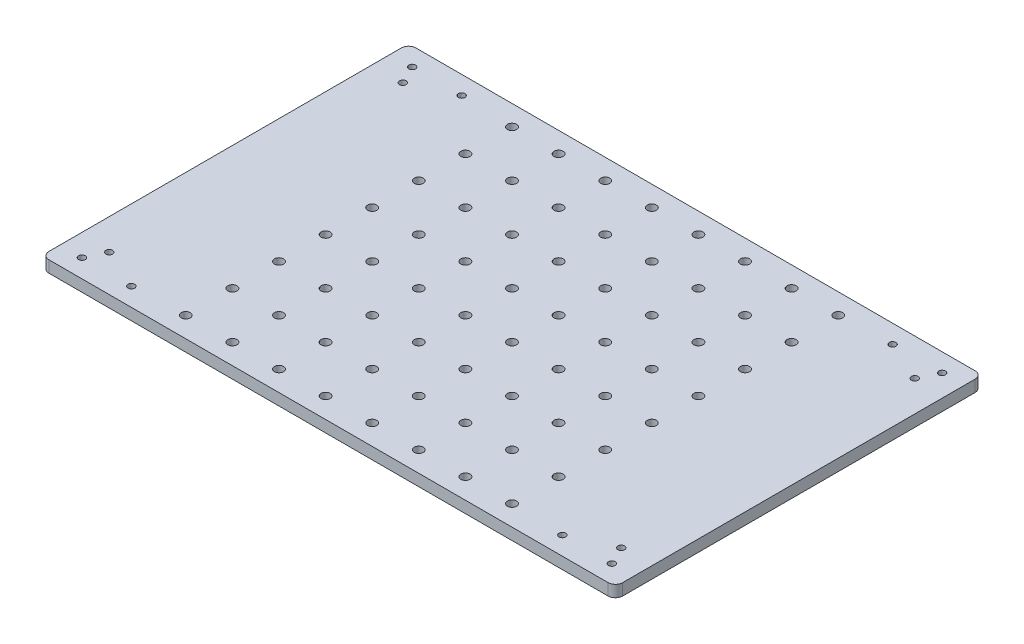
from build123d import *

# Parameters (mm, degrees)
SKETCH1_W                      = 312.7
SKETCH1_H                      = 200
BOSS_EXTRUDE1_DEPTH            = 6.35
FILLET1_R                      = 4
F_6_CLEARANCE_HOLE1_AT_2_COUNT = 2
F_6_CLEARANCE_HOLE1_AT_2_PITCH = 26.9494
F_6_CLEARANCE_HOLE1_AT_3_COUNT = 2
F_6_CLEARANCE_HOLE1_AT_3_PITCH = 11.125788882
LPATTERN2_COUNT                = 8
LPATTERN2_PITCH                = 25.4
LPATTERN3_COUNT                = 8
LPATTERN3_PITCH                = 25.4


with BuildPart() as part:
    # Sketch1 → Boss-Extrude1 (new body)
    with BuildSketch(Plane(origin=(0, 0, 0), x_dir=(1, 0, 0), z_dir=(0, 1, 0))):
        Rectangle(SKETCH1_W, SKETCH1_H)
    extrude(amount=BOSS_EXTRUDE1_DEPTH)

    # Fillet1
    fillet1_edges = [part.edges().sort_by_distance(p)[0] for p in [
        (156.35, 3.175, 100),
        (-156.35, 3.175, 100),
        (-156.35, 3.175, -100),
        (156.35, 3.175, -100),
    ]]
    fillet(fillet1_edges, radius=FILLET1_R)

    # Sketch4 → #6 Clearance Hole1 (revolve, cut)
    with BuildSketch(Plane(origin=(-144.412, 6.35, -90), x_dir=(0, 0, 1), z_dir=(1, 0, 0))):
        Polygon((0, 0), (0, 7.4488539), (1.8288, 6.35), (1.8288, 0), align=None)
    f_6_clearance_hole1 = revolve(axis=Axis((-144.412, 12.7, -90), (0, -1, 0)), mode=Mode.SUBTRACT)

    # #6 Clearance Hole1 at 2: #6 Clearance Hole1 ×2
    with Locations(*[(i * F_6_CLEARANCE_HOLE1_AT_2_PITCH, 0, 0) for i in range(1, F_6_CLEARANCE_HOLE1_AT_2_COUNT)]):
        add(f_6_clearance_hole1, mode=Mode.SUBTRACT)

    # #6 Clearance Hole1 at 3: #6 Clearance Hole1 ×2
    with Locations(*[Vector(0.438332962, 0, 0.898812669) * (i * F_6_CLEARANCE_HOLE1_AT_3_PITCH) for i in range(1, F_6_CLEARANCE_HOLE1_AT_3_COUNT)]):
        add(f_6_clearance_hole1, mode=Mode.SUBTRACT)

    # Mirror1: #6 Clearance Hole1 across plane
    add(f_6_clearance_hole1.mirror(Plane.XY), mode=Mode.SUBTRACT)

    # Mirror1 copy 1 sketch → Mirror1 copy 1 (revolve, cut)
    with BuildSketch(Plane(origin=(-117.4626, 6.35, 90), x_dir=(0, 0, -1), z_dir=(1, 0, 0))):
        Polygon((0, 0), (0, -7.4488539), (1.8288, -6.35), (1.8288, 0), align=None)
    revolve(axis=Axis((-117.4626, 12.7, 90), (0, 1, 0)), mode=Mode.SUBTRACT)

    # Mirror1 copy 2 sketch → Mirror1 copy 2 (revolve, cut)
    with BuildSketch(Plane(origin=(-139.5352, 6.35, 80), x_dir=(0, 0, -1), z_dir=(1, 0, 0))):
        Polygon((0, 0), (0, -7.4488539), (1.8288, -6.35), (1.8288, 0), align=None)
    revolve(axis=Axis((-139.5352, 12.7, 80), (0, 1, 0)), mode=Mode.SUBTRACT)

    # Mirror2: #6 Clearance Hole1 across plane
    add(f_6_clearance_hole1.mirror(Plane(origin=(0, 0, 0), x_dir=(0, 0, 1), z_dir=(1, 0, 0))), mode=Mode.SUBTRACT)

    # Mirror2 copy 1 sketch → Mirror2 copy 1 (revolve, cut)
    with BuildSketch(Plane(origin=(144.412, 6.35, 90), x_dir=(0, 0, -1), z_dir=(-1, 0, 0))):
        Polygon((0, 0), (0, 7.4488539), (1.8288, 6.35), (1.8288, 0), align=None)
    revolve(axis=Axis((144.412, 12.7, 90), (0, -1, 0)), mode=Mode.SUBTRACT)

    # Mirror2 copy 2 sketch → Mirror2 copy 2 (revolve, cut)
    with BuildSketch(Plane(origin=(117.4626, 6.35, 90), x_dir=(0, 0, -1), z_dir=(-1, 0, 0))):
        Polygon((0, 0), (0, 7.4488539), (1.8288, 6.35), (1.8288, 0), align=None)
    revolve(axis=Axis((117.4626, 12.7, 90), (0, -1, 0)), mode=Mode.SUBTRACT)

    # Mirror2 copy 3 sketch → Mirror2 copy 3 (revolve, cut)
    with BuildSketch(Plane(origin=(139.5352, 6.35, 80), x_dir=(0, 0, -1), z_dir=(-1, 0, 0))):
        Polygon((0, 0), (0, 7.4488539), (1.8288, 6.35), (1.8288, 0), align=None)
    revolve(axis=Axis((139.5352, 12.7, 80), (0, -1, 0)), mode=Mode.SUBTRACT)

    # Mirror2 copy 4 sketch → Mirror2 copy 4 (revolve, cut)
    with BuildSketch(Plane(origin=(117.4626, 6.35, -90), x_dir=(0, 0, 1), z_dir=(-1, 0, 0))):
        Polygon((0, 0), (0, -7.4488539), (1.8288, -6.35), (1.8288, 0), align=None)
    revolve(axis=Axis((117.4626, 12.7, -90), (0, 1, 0)), mode=Mode.SUBTRACT)

    # Mirror2 copy 5 sketch → Mirror2 copy 5 (revolve, cut)
    with BuildSketch(Plane(origin=(139.5352, 6.35, -80), x_dir=(0, 0, 1), z_dir=(-1, 0, 0))):
        Polygon((0, 0), (0, -7.4488539), (1.8288, -6.35), (1.8288, 0), align=None)
    revolve(axis=Axis((139.5352, 12.7, -80), (0, 1, 0)), mode=Mode.SUBTRACT)

    # Sketch9 → #10 Clearance Hole3 (revolve, cut)
    with BuildSketch(Plane(origin=(-88.9, 6.35, 88.9), x_dir=(0, 0, 1), z_dir=(1, 0, 0))):
        Polygon((0, 0), (0, 7.845662253), (2.4892, 6.35), (2.4892, 0), align=None)
    f_10_clearance_hole3 = revolve(axis=Axis((-88.9, 12.7, 88.9), (0, -1, 0)), mode=Mode.SUBTRACT)

    # LPattern2: #10 Clearance Hole3 ×8
    with Locations(*[(0, 0, -i * LPATTERN2_PITCH) for i in range(1, LPATTERN2_COUNT)]):
        add(f_10_clearance_hole3, mode=Mode.SUBTRACT)

    # LPattern3: #10 Clearance Hole3 ×8
    with Locations(*[(i * LPATTERN3_PITCH, 0, 0) for i in range(1, LPATTERN3_COUNT)]):
        add(f_10_clearance_hole3, mode=Mode.SUBTRACT)

    # LPattern3 copy 1 sketch → LPattern3 copy 1 (revolve, cut)
    with BuildSketch(Plane(origin=(-63.5, 6.35, 63.5), x_dir=(0, 0, 1), z_dir=(1, 0, 0))):
        Polygon((0, 0), (0, 7.845662253), (2.4892, 6.35), (2.4892, 0), align=None)
    revolve(axis=Axis((-63.5, 12.7, 63.5), (0, -1, 0)), mode=Mode.SUBTRACT)

    # LPattern3 copy 2 sketch → LPattern3 copy 2 (revolve, cut)
    with BuildSketch(Plane(origin=(-38.1, 6.35, 63.5), x_dir=(0, 0, 1), z_dir=(1, 0, 0))):
        Polygon((0, 0), (0, 7.845662253), (2.4892, 6.35), (2.4892, 0), align=None)
    revolve(axis=Axis((-38.1, 12.7, 63.5), (0, -1, 0)), mode=Mode.SUBTRACT)

    # LPattern3 copy 3 sketch → LPattern3 copy 3 (revolve, cut)
    with BuildSketch(Plane(origin=(-12.7, 6.35, 63.5), x_dir=(0, 0, 1), z_dir=(1, 0, 0))):
        Polygon((0, 0), (0, 7.845662253), (2.4892, 6.35), (2.4892, 0), align=None)
    revolve(axis=Axis((-12.7, 12.7, 63.5), (0, -1, 0)), mode=Mode.SUBTRACT)

    # LPattern3 copy 4 sketch → LPattern3 copy 4 (revolve, cut)
    with BuildSketch(Plane(origin=(12.7, 6.35, 63.5), x_dir=(0, 0, 1), z_dir=(1, 0, 0))):
        Polygon((0, 0), (0, 7.845662253), (2.4892, 6.35), (2.4892, 0), align=None)
    revolve(axis=Axis((12.7, 12.7, 63.5), (0, -1, 0)), mode=Mode.SUBTRACT)

    # LPattern3 copy 5 sketch → LPattern3 copy 5 (revolve, cut)
    with BuildSketch(Plane(origin=(38.1, 6.35, 63.5), x_dir=(0, 0, 1), z_dir=(1, 0, 0))):
        Polygon((0, 0), (0, 7.845662253), (2.4892, 6.35), (2.4892, 0), align=None)
    revolve(axis=Axis((38.1, 12.7, 63.5), (0, -1, 0)), mode=Mode.SUBTRACT)

    # LPattern3 copy 6 sketch → LPattern3 copy 6 (revolve, cut)
    with BuildSketch(Plane(origin=(63.5, 6.35, 63.5), x_dir=(0, 0, 1), z_dir=(1, 0, 0))):
        Polygon((0, 0), (0, 7.845662253), (2.4892, 6.35), (2.4892, 0), align=None)
    revolve(axis=Axis((63.5, 12.7, 63.5), (0, -1, 0)), mode=Mode.SUBTRACT)

    # LPattern3 copy 7 sketch → LPattern3 copy 7 (revolve, cut)
    with BuildSketch(Plane(origin=(88.9, 6.35, 63.5), x_dir=(0, 0, 1), z_dir=(1, 0, 0))):
        Polygon((0, 0), (0, 7.845662253), (2.4892, 6.35), (2.4892, 0), align=None)
    revolve(axis=Axis((88.9, 12.7, 63.5), (0, -1, 0)), mode=Mode.SUBTRACT)

    # LPattern3 copy 8 sketch → LPattern3 copy 8 (revolve, cut)
    with BuildSketch(Plane(origin=(-63.5, 6.35, 38.1), x_dir=(0, 0, 1), z_dir=(1, 0, 0))):
        Polygon((0, 0), (0, 7.845662253), (2.4892, 6.35), (2.4892, 0), align=None)
    revolve(axis=Axis((-63.5, 12.7, 38.1), (0, -1, 0)), mode=Mode.SUBTRACT)

    # LPattern3 copy 9 sketch → LPattern3 copy 9 (revolve, cut)
    with BuildSketch(Plane(origin=(-38.1, 6.35, 38.1), x_dir=(0, 0, 1), z_dir=(1, 0, 0))):
        Polygon((0, 0), (0, 7.845662253), (2.4892, 6.35), (2.4892, 0), align=None)
    revolve(axis=Axis((-38.1, 12.7, 38.1), (0, -1, 0)), mode=Mode.SUBTRACT)

    # LPattern3 copy 10 sketch → LPattern3 copy 10 (revolve, cut)
    with BuildSketch(Plane(origin=(-12.7, 6.35, 38.1), x_dir=(0, 0, 1), z_dir=(1, 0, 0))):
        Polygon((0, 0), (0, 7.845662253), (2.4892, 6.35), (2.4892, 0), align=None)
    revolve(axis=Axis((-12.7, 12.7, 38.1), (0, -1, 0)), mode=Mode.SUBTRACT)

    # LPattern3 copy 11 sketch → LPattern3 copy 11 (revolve, cut)
    with BuildSketch(Plane(origin=(12.7, 6.35, 38.1), x_dir=(0, 0, 1), z_dir=(1, 0, 0))):
        Polygon((0, 0), (0, 7.845662253), (2.4892, 6.35), (2.4892, 0), align=None)
    revolve(axis=Axis((12.7, 12.7, 38.1), (0, -1, 0)), mode=Mode.SUBTRACT)

    # LPattern3 copy 12 sketch → LPattern3 copy 12 (revolve, cut)
    with BuildSketch(Plane(origin=(38.1, 6.35, 38.1), x_dir=(0, 0, 1), z_dir=(1, 0, 0))):
        Polygon((0, 0), (0, 7.845662253), (2.4892, 6.35), (2.4892, 0), align=None)
    revolve(axis=Axis((38.1, 12.7, 38.1), (0, -1, 0)), mode=Mode.SUBTRACT)

    # LPattern3 copy 13 sketch → LPattern3 copy 13 (revolve, cut)
    with BuildSketch(Plane(origin=(63.5, 6.35, 38.1), x_dir=(0, 0, 1), z_dir=(1, 0, 0))):
        Polygon((0, 0), (0, 7.845662253), (2.4892, 6.35), (2.4892, 0), align=None)
    revolve(axis=Axis((63.5, 12.7, 38.1), (0, -1, 0)), mode=Mode.SUBTRACT)

    # LPattern3 copy 14 sketch → LPattern3 copy 14 (revolve, cut)
    with BuildSketch(Plane(origin=(88.9, 6.35, 38.1), x_dir=(0, 0, 1), z_dir=(1, 0, 0))):
        Polygon((0, 0), (0, 7.845662253), (2.4892, 6.35), (2.4892, 0), align=None)
    revolve(axis=Axis((88.9, 12.7, 38.1), (0, -1, 0)), mode=Mode.SUBTRACT)

    # LPattern3 copy 15 sketch → LPattern3 copy 15 (revolve, cut)
    with BuildSketch(Plane(origin=(-63.5, 6.35, 12.7), x_dir=(0, 0, 1), z_dir=(1, 0, 0))):
        Polygon((0, 0), (0, 7.845662253), (2.4892, 6.35), (2.4892, 0), align=None)
    revolve(axis=Axis((-63.5, 12.7, 12.7), (0, -1, 0)), mode=Mode.SUBTRACT)

    # LPattern3 copy 16 sketch → LPattern3 copy 16 (revolve, cut)
    with BuildSketch(Plane(origin=(-38.1, 6.35, 12.7), x_dir=(0, 0, 1), z_dir=(1, 0, 0))):
        Polygon((0, 0), (0, 7.845662253), (2.4892, 6.35), (2.4892, 0), align=None)
    revolve(axis=Axis((-38.1, 12.7, 12.7), (0, -1, 0)), mode=Mode.SUBTRACT)

    # LPattern3 copy 17 sketch → LPattern3 copy 17 (revolve, cut)
    with BuildSketch(Plane(origin=(-12.7, 6.35, 12.7), x_dir=(0, 0, 1), z_dir=(1, 0, 0))):
        Polygon((0, 0), (0, 7.845662253), (2.4892, 6.35), (2.4892, 0), align=None)
    revolve(axis=Axis((-12.7, 12.7, 12.7), (0, -1, 0)), mode=Mode.SUBTRACT)

    # LPattern3 copy 18 sketch → LPattern3 copy 18 (revolve, cut)
    with BuildSketch(Plane(origin=(12.7, 6.35, 12.7), x_dir=(0, 0, 1), z_dir=(1, 0, 0))):
        Polygon((0, 0), (0, 7.845662253), (2.4892, 6.35), (2.4892, 0), align=None)
    revolve(axis=Axis((12.7, 12.7, 12.7), (0, -1, 0)), mode=Mode.SUBTRACT)

    # LPattern3 copy 19 sketch → LPattern3 copy 19 (revolve, cut)
    with BuildSketch(Plane(origin=(38.1, 6.35, 12.7), x_dir=(0, 0, 1), z_dir=(1, 0, 0))):
        Polygon((0, 0), (0, 7.845662253), (2.4892, 6.35), (2.4892, 0), align=None)
    revolve(axis=Axis((38.1, 12.7, 12.7), (0, -1, 0)), mode=Mode.SUBTRACT)

    # LPattern3 copy 20 sketch → LPattern3 copy 20 (revolve, cut)
    with BuildSketch(Plane(origin=(63.5, 6.35, 12.7), x_dir=(0, 0, 1), z_dir=(1, 0, 0))):
        Polygon((0, 0), (0, 7.845662253), (2.4892, 6.35), (2.4892, 0), align=None)
    revolve(axis=Axis((63.5, 12.7, 12.7), (0, -1, 0)), mode=Mode.SUBTRACT)

    # LPattern3 copy 21 sketch → LPattern3 copy 21 (revolve, cut)
    with BuildSketch(Plane(origin=(88.9, 6.35, 12.7), x_dir=(0, 0, 1), z_dir=(1, 0, 0))):
        Polygon((0, 0), (0, 7.845662253), (2.4892, 6.35), (2.4892, 0), align=None)
    revolve(axis=Axis((88.9, 12.7, 12.7), (0, -1, 0)), mode=Mode.SUBTRACT)

    # LPattern3 copy 22 sketch → LPattern3 copy 22 (revolve, cut)
    with BuildSketch(Plane(origin=(-63.5, 6.35, -12.7), x_dir=(0, 0, 1), z_dir=(1, 0, 0))):
        Polygon((0, 0), (0, 7.845662253), (2.4892, 6.35), (2.4892, 0), align=None)
    revolve(axis=Axis((-63.5, 12.7, -12.7), (0, -1, 0)), mode=Mode.SUBTRACT)

    # LPattern3 copy 23 sketch → LPattern3 copy 23 (revolve, cut)
    with BuildSketch(Plane(origin=(-38.1, 6.35, -12.7), x_dir=(0, 0, 1), z_dir=(1, 0, 0))):
        Polygon((0, 0), (0, 7.845662253), (2.4892, 6.35), (2.4892, 0), align=None)
    revolve(axis=Axis((-38.1, 12.7, -12.7), (0, -1, 0)), mode=Mode.SUBTRACT)

    # LPattern3 copy 24 sketch → LPattern3 copy 24 (revolve, cut)
    with BuildSketch(Plane(origin=(-12.7, 6.35, -12.7), x_dir=(0, 0, 1), z_dir=(1, 0, 0))):
        Polygon((0, 0), (0, 7.845662253), (2.4892, 6.35), (2.4892, 0), align=None)
    revolve(axis=Axis((-12.7, 12.7, -12.7), (0, -1, 0)), mode=Mode.SUBTRACT)

    # LPattern3 copy 25 sketch → LPattern3 copy 25 (revolve, cut)
    with BuildSketch(Plane(origin=(12.7, 6.35, -12.7), x_dir=(0, 0, 1), z_dir=(1, 0, 0))):
        Polygon((0, 0), (0, 7.845662253), (2.4892, 6.35), (2.4892, 0), align=None)
    revolve(axis=Axis((12.7, 12.7, -12.7), (0, -1, 0)), mode=Mode.SUBTRACT)

    # LPattern3 copy 26 sketch → LPattern3 copy 26 (revolve, cut)
    with BuildSketch(Plane(origin=(38.1, 6.35, -12.7), x_dir=(0, 0, 1), z_dir=(1, 0, 0))):
        Polygon((0, 0), (0, 7.845662253), (2.4892, 6.35), (2.4892, 0), align=None)
    revolve(axis=Axis((38.1, 12.7, -12.7), (0, -1, 0)), mode=Mode.SUBTRACT)

    # LPattern3 copy 27 sketch → LPattern3 copy 27 (revolve, cut)
    with BuildSketch(Plane(origin=(63.5, 6.35, -12.7), x_dir=(0, 0, 1), z_dir=(1, 0, 0))):
        Polygon((0, 0), (0, 7.845662253), (2.4892, 6.35), (2.4892, 0), align=None)
    revolve(axis=Axis((63.5, 12.7, -12.7), (0, -1, 0)), mode=Mode.SUBTRACT)

    # LPattern3 copy 28 sketch → LPattern3 copy 28 (revolve, cut)
    with BuildSketch(Plane(origin=(88.9, 6.35, -12.7), x_dir=(0, 0, 1), z_dir=(1, 0, 0))):
        Polygon((0, 0), (0, 7.845662253), (2.4892, 6.35), (2.4892, 0), align=None)
    revolve(axis=Axis((88.9, 12.7, -12.7), (0, -1, 0)), mode=Mode.SUBTRACT)

    # LPattern3 copy 29 sketch → LPattern3 copy 29 (revolve, cut)
    with BuildSketch(Plane(origin=(-63.5, 6.35, -38.1), x_dir=(0, 0, 1), z_dir=(1, 0, 0))):
        Polygon((0, 0), (0, 7.845662253), (2.4892, 6.35), (2.4892, 0), align=None)
    revolve(axis=Axis((-63.5, 12.7, -38.1), (0, -1, 0)), mode=Mode.SUBTRACT)

    # LPattern3 copy 30 sketch → LPattern3 copy 30 (revolve, cut)
    with BuildSketch(Plane(origin=(-38.1, 6.35, -38.1), x_dir=(0, 0, 1), z_dir=(1, 0, 0))):
        Polygon((0, 0), (0, 7.845662253), (2.4892, 6.35), (2.4892, 0), align=None)
    revolve(axis=Axis((-38.1, 12.7, -38.1), (0, -1, 0)), mode=Mode.SUBTRACT)

    # LPattern3 copy 31 sketch → LPattern3 copy 31 (revolve, cut)
    with BuildSketch(Plane(origin=(-12.7, 6.35, -38.1), x_dir=(0, 0, 1), z_dir=(1, 0, 0))):
        Polygon((0, 0), (0, 7.845662253), (2.4892, 6.35), (2.4892, 0), align=None)
    revolve(axis=Axis((-12.7, 12.7, -38.1), (0, -1, 0)), mode=Mode.SUBTRACT)

    # LPattern3 copy 32 sketch → LPattern3 copy 32 (revolve, cut)
    with BuildSketch(Plane(origin=(12.7, 6.35, -38.1), x_dir=(0, 0, 1), z_dir=(1, 0, 0))):
        Polygon((0, 0), (0, 7.845662253), (2.4892, 6.35), (2.4892, 0), align=None)
    revolve(axis=Axis((12.7, 12.7, -38.1), (0, -1, 0)), mode=Mode.SUBTRACT)

    # LPattern3 copy 33 sketch → LPattern3 copy 33 (revolve, cut)
    with BuildSketch(Plane(origin=(38.1, 6.35, -38.1), x_dir=(0, 0, 1), z_dir=(1, 0, 0))):
        Polygon((0, 0), (0, 7.845662253), (2.4892, 6.35), (2.4892, 0), align=None)
    revolve(axis=Axis((38.1, 12.7, -38.1), (0, -1, 0)), mode=Mode.SUBTRACT)

    # LPattern3 copy 34 sketch → LPattern3 copy 34 (revolve, cut)
    with BuildSketch(Plane(origin=(63.5, 6.35, -38.1), x_dir=(0, 0, 1), z_dir=(1, 0, 0))):
        Polygon((0, 0), (0, 7.845662253), (2.4892, 6.35), (2.4892, 0), align=None)
    revolve(axis=Axis((63.5, 12.7, -38.1), (0, -1, 0)), mode=Mode.SUBTRACT)

    # LPattern3 copy 35 sketch → LPattern3 copy 35 (revolve, cut)
    with BuildSketch(Plane(origin=(88.9, 6.35, -38.1), x_dir=(0, 0, 1), z_dir=(1, 0, 0))):
        Polygon((0, 0), (0, 7.845662253), (2.4892, 6.35), (2.4892, 0), align=None)
    revolve(axis=Axis((88.9, 12.7, -38.1), (0, -1, 0)), mode=Mode.SUBTRACT)

    # LPattern3 copy 36 sketch → LPattern3 copy 36 (revolve, cut)
    with BuildSketch(Plane(origin=(-63.5, 6.35, -63.5), x_dir=(0, 0, 1), z_dir=(1, 0, 0))):
        Polygon((0, 0), (0, 7.845662253), (2.4892, 6.35), (2.4892, 0), align=None)
    revolve(axis=Axis((-63.5, 12.7, -63.5), (0, -1, 0)), mode=Mode.SUBTRACT)

    # LPattern3 copy 37 sketch → LPattern3 copy 37 (revolve, cut)
    with BuildSketch(Plane(origin=(-38.1, 6.35, -63.5), x_dir=(0, 0, 1), z_dir=(1, 0, 0))):
        Polygon((0, 0), (0, 7.845662253), (2.4892, 6.35), (2.4892, 0), align=None)
    revolve(axis=Axis((-38.1, 12.7, -63.5), (0, -1, 0)), mode=Mode.SUBTRACT)

    # LPattern3 copy 38 sketch → LPattern3 copy 38 (revolve, cut)
    with BuildSketch(Plane(origin=(-12.7, 6.35, -63.5), x_dir=(0, 0, 1), z_dir=(1, 0, 0))):
        Polygon((0, 0), (0, 7.845662253), (2.4892, 6.35), (2.4892, 0), align=None)
    revolve(axis=Axis((-12.7, 12.7, -63.5), (0, -1, 0)), mode=Mode.SUBTRACT)

    # LPattern3 copy 39 sketch → LPattern3 copy 39 (revolve, cut)
    with BuildSketch(Plane(origin=(12.7, 6.35, -63.5), x_dir=(0, 0, 1), z_dir=(1, 0, 0))):
        Polygon((0, 0), (0, 7.845662253), (2.4892, 6.35), (2.4892, 0), align=None)
    revolve(axis=Axis((12.7, 12.7, -63.5), (0, -1, 0)), mode=Mode.SUBTRACT)

    # LPattern3 copy 40 sketch → LPattern3 copy 40 (revolve, cut)
    with BuildSketch(Plane(origin=(38.1, 6.35, -63.5), x_dir=(0, 0, 1), z_dir=(1, 0, 0))):
        Polygon((0, 0), (0, 7.845662253), (2.4892, 6.35), (2.4892, 0), align=None)
    revolve(axis=Axis((38.1, 12.7, -63.5), (0, -1, 0)), mode=Mode.SUBTRACT)

    # LPattern3 copy 41 sketch → LPattern3 copy 41 (revolve, cut)
    with BuildSketch(Plane(origin=(63.5, 6.35, -63.5), x_dir=(0, 0, 1), z_dir=(1, 0, 0))):
        Polygon((0, 0), (0, 7.845662253), (2.4892, 6.35), (2.4892, 0), align=None)
    revolve(axis=Axis((63.5, 12.7, -63.5), (0, -1, 0)), mode=Mode.SUBTRACT)

    # LPattern3 copy 42 sketch → LPattern3 copy 42 (revolve, cut)
    with BuildSketch(Plane(origin=(88.9, 6.35, -63.5), x_dir=(0, 0, 1), z_dir=(1, 0, 0))):
        Polygon((0, 0), (0, 7.845662253), (2.4892, 6.35), (2.4892, 0), align=None)
    revolve(axis=Axis((88.9, 12.7, -63.5), (0, -1, 0)), mode=Mode.SUBTRACT)

    # LPattern3 copy 43 sketch → LPattern3 copy 43 (revolve, cut)
    with BuildSketch(Plane(origin=(-63.5, 6.35, -88.9), x_dir=(0, 0, 1), z_dir=(1, 0, 0))):
        Polygon((0, 0), (0, 7.845662253), (2.4892, 6.35), (2.4892, 0), align=None)
    revolve(axis=Axis((-63.5, 12.7, -88.9), (0, -1, 0)), mode=Mode.SUBTRACT)

    # LPattern3 copy 44 sketch → LPattern3 copy 44 (revolve, cut)
    with BuildSketch(Plane(origin=(-38.1, 6.35, -88.9), x_dir=(0, 0, 1), z_dir=(1, 0, 0))):
        Polygon((0, 0), (0, 7.845662253), (2.4892, 6.35), (2.4892, 0), align=None)
    revolve(axis=Axis((-38.1, 12.7, -88.9), (0, -1, 0)), mode=Mode.SUBTRACT)

    # LPattern3 copy 45 sketch → LPattern3 copy 45 (revolve, cut)
    with BuildSketch(Plane(origin=(-12.7, 6.35, -88.9), x_dir=(0, 0, 1), z_dir=(1, 0, 0))):
        Polygon((0, 0), (0, 7.845662253), (2.4892, 6.35), (2.4892, 0), align=None)
    revolve(axis=Axis((-12.7, 12.7, -88.9), (0, -1, 0)), mode=Mode.SUBTRACT)

    # LPattern3 copy 46 sketch → LPattern3 copy 46 (revolve, cut)
    with BuildSketch(Plane(origin=(12.7, 6.35, -88.9), x_dir=(0, 0, 1), z_dir=(1, 0, 0))):
        Polygon((0, 0), (0, 7.845662253), (2.4892, 6.35), (2.4892, 0), align=None)
    revolve(axis=Axis((12.7, 12.7, -88.9), (0, -1, 0)), mode=Mode.SUBTRACT)

    # LPattern3 copy 47 sketch → LPattern3 copy 47 (revolve, cut)
    with BuildSketch(Plane(origin=(38.1, 6.35, -88.9), x_dir=(0, 0, 1), z_dir=(1, 0, 0))):
        Polygon((0, 0), (0, 7.845662253), (2.4892, 6.35), (2.4892, 0), align=None)
    revolve(axis=Axis((38.1, 12.7, -88.9), (0, -1, 0)), mode=Mode.SUBTRACT)

    # LPattern3 copy 48 sketch → LPattern3 copy 48 (revolve, cut)
    with BuildSketch(Plane(origin=(63.5, 6.35, -88.9), x_dir=(0, 0, 1), z_dir=(1, 0, 0))):
        Polygon((0, 0), (0, 7.845662253), (2.4892, 6.35), (2.4892, 0), align=None)
    revolve(axis=Axis((63.5, 12.7, -88.9), (0, -1, 0)), mode=Mode.SUBTRACT)

    # LPattern3 copy 49 sketch → LPattern3 copy 49 (revolve, cut)
    with BuildSketch(Plane(origin=(88.9, 6.35, -88.9), x_dir=(0, 0, 1), z_dir=(1, 0, 0))):
        Polygon((0, 0), (0, 7.845662253), (2.4892, 6.35), (2.4892, 0), align=None)
    revolve(axis=Axis((88.9, 12.7, -88.9), (0, -1, 0)), mode=Mode.SUBTRACT)


solid = part.part
